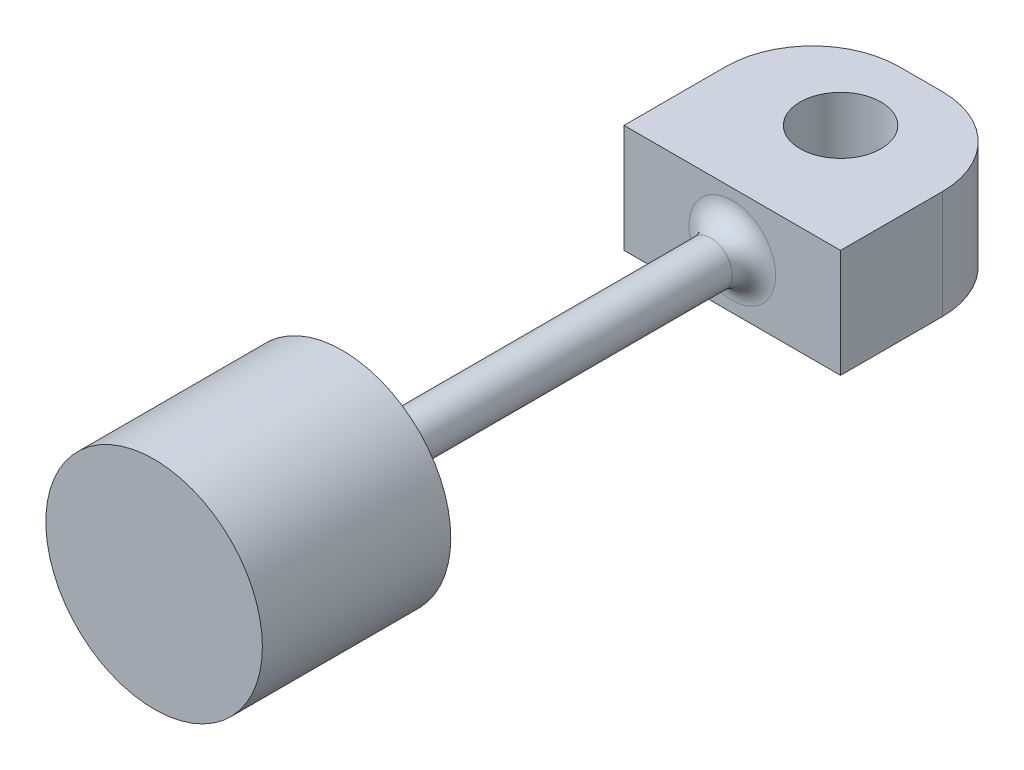
from build123d import *

# Parameters (mm, degrees)
SKETCH1_R           = 6.35
BOSS_EXTRUDE1_DEPTH = 11.049
SKETCH2_R           = 1.27
BOSS_EXTRUDE2_DEPTH = 22.86
FILLET1_R           = 1.27
SKETCH3_W           = 12.7
SKETCH3_H           = 6.35
BOSS_EXTRUDE3_DEPTH = 11.049
FILLET2_R           = 1.27
FILLET3_R           = 5.08
SKETCH4_R           = 2.3749
CUT_EXTRUDE1_DEPTH  = 10.525


with BuildPart() as part:
    # Sketch1 → Boss-Extrude1 (new body)
    with BuildSketch(Plane.XY):
        Circle(SKETCH1_R)
    extrude(amount=-BOSS_EXTRUDE1_DEPTH)

    # Sketch2 → Boss-Extrude2 (add)
    with BuildSketch(Plane(origin=(0, 0, -11.049), x_dir=(-1, 0, 0), z_dir=(0, 0, -1))):
        Circle(SKETCH2_R)
    extrude(amount=BOSS_EXTRUDE2_DEPTH)

    # Fillet1
    fillet1_edges = [part.edges().sort_by_distance(p)[0] for p in [
        (1.27, 0, -11.049),
    ]]
    fillet(fillet1_edges, radius=FILLET1_R)

    # Sketch3 → Boss-Extrude3 (add)
    with BuildSketch(Plane(origin=(0, 0, -33.909), x_dir=(-1, 0, 0), z_dir=(0, 0, -1))):
        Rectangle(SKETCH3_W, SKETCH3_H)
    extrude(amount=BOSS_EXTRUDE3_DEPTH)

    # Fillet2
    fillet2_edges = [part.edges().sort_by_distance(p)[0] for p in [
        (1.27, 0, -33.909),
    ]]
    fillet(fillet2_edges, radius=FILLET2_R)

    # Fillet3
    fillet3_edges = [part.edges().sort_by_distance(p)[0] for p in [
        (6.35, 0, -44.958),
        (-6.35, 0, -44.958),
    ]]
    fillet(fillet3_edges, radius=FILLET3_R)

    # Sketch4 → Cut-Extrude1 (cut, through all)
    with BuildSketch(Plane(origin=(0, 3.175, 0), x_dir=(1, 0, 0), z_dir=(0, 1, 0))):
        with Locations((0, 40.259)):
            Circle(SKETCH4_R)
    extrude(amount=-CUT_EXTRUDE1_DEPTH, mode=Mode.SUBTRACT)


solid = part.part
